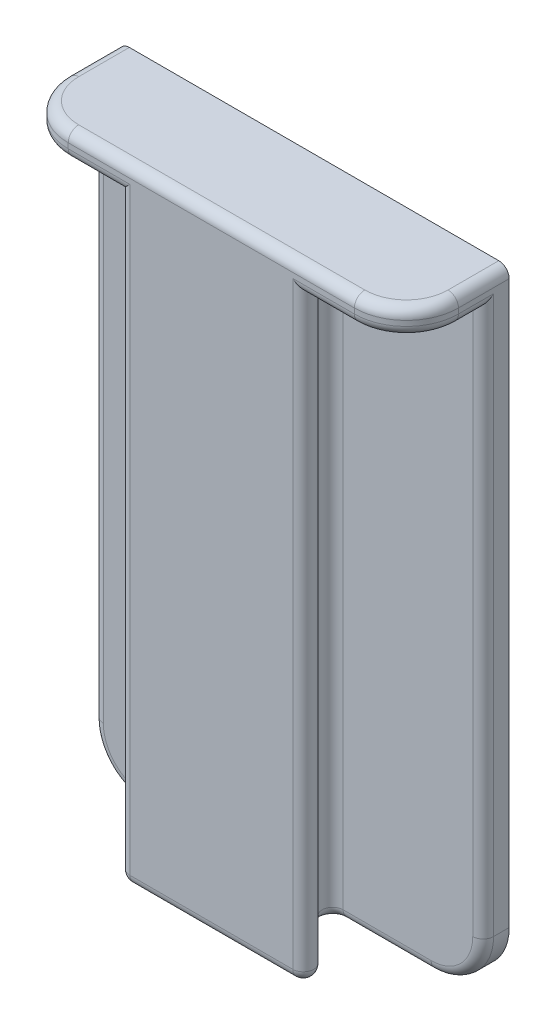
from build123d import *

# Parameters (mm, degrees)
SKETCH1_W           = 75
SKETCH1_H           = 115
BOSS_EXTRUDE1_DEPTH = 5
BOSS_EXTRUDE2_DEPTH = 115
FILLET1_R           = 2
SKETCH5_W           = 75
SKETCH5_H           = 19.75
BOSS_EXTRUDE3_DEPTH = 5
FILLET2_R           = 10
FILLET3_R           = 2


with BuildPart() as part:
    # Sketch1 → Boss-Extrude1 (new body)
    with BuildSketch(Plane.XY):
        Rectangle(SKETCH1_W, SKETCH1_H)
    extrude(amount=BOSS_EXTRUDE1_DEPTH)

    # Sketch4 → Boss-Extrude2 (add)
    with BuildSketch(Plane(origin=(0, 57.5, 0), x_dir=(1, 0, 0), z_dir=(0, 1, 0))):
        Polygon((-5.75, -5), (5.75, -5), (20.5, -19.75), (-20.5, -19.75), align=None)
    extrude(amount=-BOSS_EXTRUDE2_DEPTH)

    # Fillet1
    fillet1_edges = [part.edges().sort_by_distance(p)[0] for p in [
        (5.75, 0, 5),
        (20.5, 0, 19.75),
        (-20.5, 0, 19.75),
        (-5.75, 0, 5),
    ]]
    fillet(fillet1_edges, radius=FILLET1_R)

    # Sketch5 → Boss-Extrude3 (add)
    with BuildSketch(Plane(origin=(0, 57.5, 0), x_dir=(1, 0, 0), z_dir=(0, 1, 0))):
        with Locations((0, -9.875)):
            Rectangle(SKETCH5_W, SKETCH5_H)
    extrude(amount=BOSS_EXTRUDE3_DEPTH)

    # Fillet2
    fillet2_edges = [part.edges().sort_by_distance(p)[0] for p in [
        (-37.5, 60, 19.75),
        (37.5, 60, 19.75),
        (37.5, -57.5, 2.5),
        (-37.5, -57.5, 2.5),
    ]]
    fillet(fillet2_edges, radius=FILLET2_R)

    # Fillet3
    fillet3_edges = [part.edges().sort_by_distance(p)[0] for p in [
        (-37.5, 5, 5),
        (-13.125, -57.5, 12.375),
        (13.125, -57.5, 12.375),
        (19.039213562, -57.5, 5),
        (0, -57.5, 19.75),
        (-17.51933194, -57.5, 18.515366865),
        (17.51933194, -57.5, 18.515366865),
        (-8.73066806, -57.5, 6.234633135),
        (8.73066806, -57.5, 6.234633135),
        (-37.5, 57.5, 7.375),
        (21.585786438, 57.5, 19.75),
        (-37.5, 62.5, 4.875),
        (0, 62.5, 19.75),
        (-21.585786438, 57.5, 19.75),
        (-34.571067812, 57.5, 16.821067812),
        (37.5, 62.5, 4.875),
        (34.571067812, 62.5, 16.821067812),
        (-34.571067812, 62.5, 16.821067812),
        (37.5, 57.5, 7.375),
        (37.5, 5, 5),
        (34.571067812, 57.5, 16.821067812),
        (-19.039213562, -57.5, 5),
        (34.571067812, -54.571067812, 5),
        (-34.571067812, -54.571067812, 5),
    ]]
    fillet(fillet3_edges, radius=FILLET3_R)


solid = part.part
